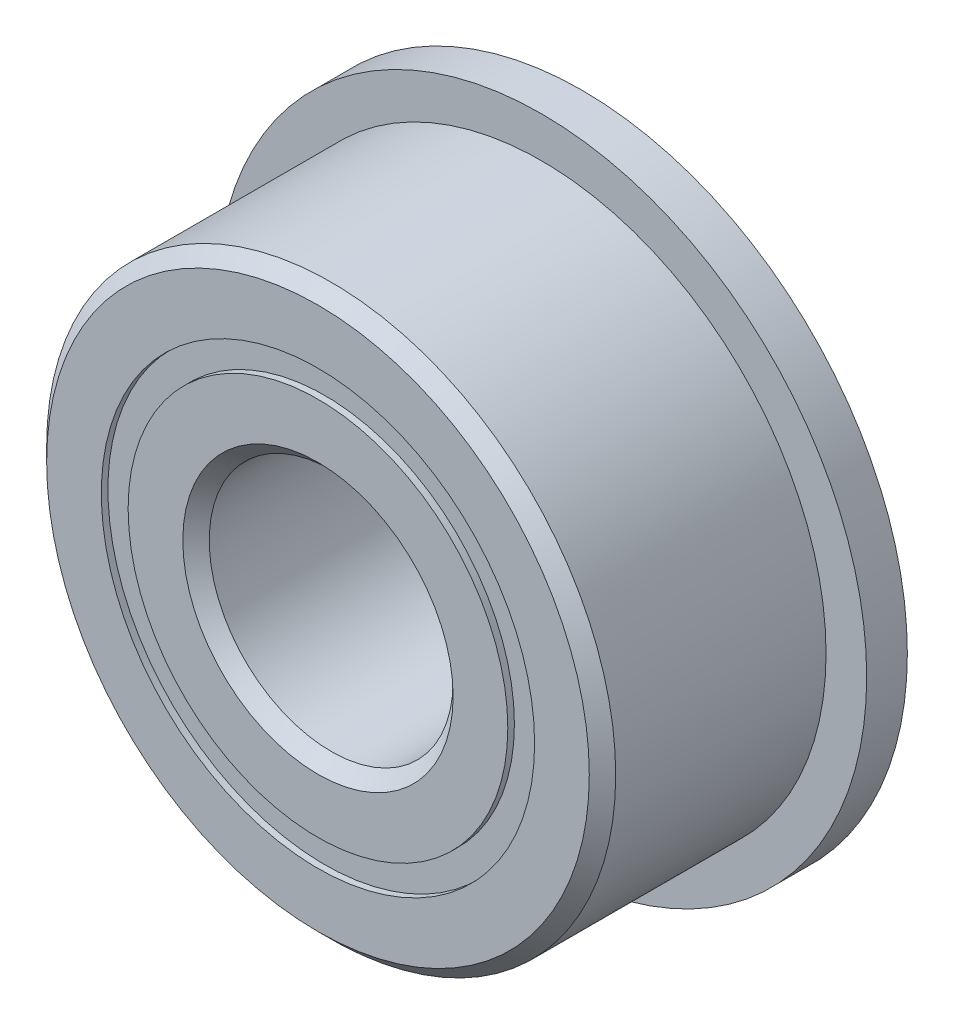
from build123d import *

# Parameters (mm, degrees)
CIRPATTERN1_COUNT = 12
SKETCH5_W         = 2.549385687
SKETCH5_H         = 1.046703296
SKETCH6_W         = 1.5875
SKETCH6_H         = 4.239148352


with BuildPart() as part:
    # Sketch1 → Revolve1 (revolve)
    with BuildSketch(Plane(origin=(0, 0, 0), x_dir=(0, 0, -1), z_dir=(1, 0, 0))):
        with BuildLine():
            Line((4.6434375, 11.1125), (-4.6434375, 11.1125))
            Line((-4.6434375, 11.1125), (-5.159375, 10.5965625))
            Line((-5.159375, 10.5965625), (-5.159375, 8.460851648))
            Line((-5.159375, 8.460851648), (-2.293055556, 8.460851648))
            ThreePointArc((-2.293055556, 8.460851648), (0, 10.289520563), (2.293055556, 8.460851648))
            Line((2.293055556, 8.460851648), (5.159375, 8.460851648))
            Line((5.159375, 8.460851648), (5.159375, 10.5965625))
            Line((5.159375, 10.5965625), (4.6434375, 11.1125))
        make_face()
    revolve(axis=Axis((0, 0, 5.159375), (0, 0, -1)))

    # Sketch6 → Revolve6 (revolve)
    with BuildSketch(Plane(origin=(0, 0, 0), x_dir=(0, 0, -1), z_dir=(1, 0, 0))):
        with Locations((4.365625, 10.580425824)):
            Rectangle(SKETCH6_W, SKETCH6_H)
    revolve(axis=Axis((0, 0, -5.159375), (0, 0, 1)))


with BuildPart() as body_2:
    # Sketch3 → Revolve3 (revolve)
    with BuildSketch(Plane(origin=(0, 0, 0), x_dir=(0, 0, -1), z_dir=(1, 0, 0))):
        with BuildLine():
            Line((-5.159375, 7.414148352), (-2.293055556, 7.414148352))
            ThreePointArc((-2.293055556, 7.414148352), (0, 5.585479437), (2.293055556, 7.414148352))
            Line((2.293055556, 7.414148352), (5.159375, 7.414148352))
            Line((5.159375, 7.414148352), (5.159375, 5.2784375))
            Line((5.159375, 5.2784375), (4.6434375, 4.7625))
            Line((4.6434375, 4.7625), (-4.6434375, 4.7625))
            Line((-4.6434375, 4.7625), (-5.159375, 5.2784375))
            Line((-5.159375, 5.2784375), (-5.159375, 7.414148352))
        make_face()
    revolve(axis=Axis((0, 0, 5.159375), (0, 0, -1)))


with BuildPart() as body_3:
    # Sketch4 → Revolve4 (revolve)
    with BuildSketch(Plane(origin=(0, 0, 0), x_dir=(0, 0, -1), z_dir=(1, 0, 0))):
        with BuildLine():
            Line((-2.352020563, 7.9375), (2.352020563, 7.9375))
            ThreePointArc((2.352020563, 7.9375), (0, 10.289520563), (-2.352020563, 7.9375))
        make_face()
    revolve(axis=Axis((0, 7.9375, 2.352020563), (0, 0, -1)))


with BuildPart() as cirpattern1_1:
    # CirPattern1: pattern copy
    add(body_3.part.rotate(Axis((0, 0, -5.159375), (0, 0, 1)), 1 * 360 / CIRPATTERN1_COUNT))


with BuildPart() as cirpattern1_2:
    # CirPattern1: pattern copy
    add(body_3.part.rotate(Axis((0, 0, -5.159375), (0, 0, 1)), 2 * 360 / CIRPATTERN1_COUNT))


with BuildPart() as cirpattern1_3:
    # CirPattern1: pattern copy
    add(body_3.part.rotate(Axis((0, 0, -5.159375), (0, 0, 1)), 3 * 360 / CIRPATTERN1_COUNT))


with BuildPart() as cirpattern1_4:
    # CirPattern1: pattern copy
    add(body_3.part.rotate(Axis((0, 0, -5.159375), (0, 0, 1)), 4 * 360 / CIRPATTERN1_COUNT))


with BuildPart() as cirpattern1_5:
    # CirPattern1: pattern copy
    add(body_3.part.rotate(Axis((0, 0, -5.159375), (0, 0, 1)), 5 * 360 / CIRPATTERN1_COUNT))


with BuildPart() as cirpattern1_6:
    # CirPattern1: pattern copy
    add(body_3.part.rotate(Axis((0, 0, -5.159375), (0, 0, 1)), 6 * 360 / CIRPATTERN1_COUNT))


with BuildPart() as cirpattern1_7:
    # CirPattern1: pattern copy
    add(body_3.part.rotate(Axis((0, 0, -5.159375), (0, 0, 1)), 7 * 360 / CIRPATTERN1_COUNT))


with BuildPart() as cirpattern1_8:
    # CirPattern1: pattern copy
    add(body_3.part.rotate(Axis((0, 0, -5.159375), (0, 0, 1)), 8 * 360 / CIRPATTERN1_COUNT))


with BuildPart() as cirpattern1_9:
    # CirPattern1: pattern copy
    add(body_3.part.rotate(Axis((0, 0, -5.159375), (0, 0, 1)), 9 * 360 / CIRPATTERN1_COUNT))


with BuildPart() as cirpattern1_10:
    # CirPattern1: pattern copy
    add(body_3.part.rotate(Axis((0, 0, -5.159375), (0, 0, 1)), 10 * 360 / CIRPATTERN1_COUNT))


with BuildPart() as cirpattern1_11:
    # CirPattern1: pattern copy
    add(body_3.part.rotate(Axis((0, 0, -5.159375), (0, 0, 1)), 11 * 360 / CIRPATTERN1_COUNT))


with BuildPart() as body_15:
    # Sketch5 → Revolve5 (revolve)
    with BuildSketch(Plane(origin=(0, 0, 0), x_dir=(0, 0, -1), z_dir=(1, 0, 0))):
        with Locations((-3.626713406, 7.9375)):
            Rectangle(SKETCH5_W, SKETCH5_H)
        with Locations((3.626713406, 7.9375)):
            Rectangle(SKETCH5_W, SKETCH5_H)
    revolve(axis=Axis((0, 0, 5.159375), (0, 0, -1)))


solid = Compound([part.part, body_2.part, body_3.part, cirpattern1_1.part, cirpattern1_2.part, cirpattern1_3.part, cirpattern1_4.part, cirpattern1_5.part, cirpattern1_6.part, cirpattern1_7.part, cirpattern1_8.part, cirpattern1_9.part, cirpattern1_10.part, cirpattern1_11.part, body_15.part])
